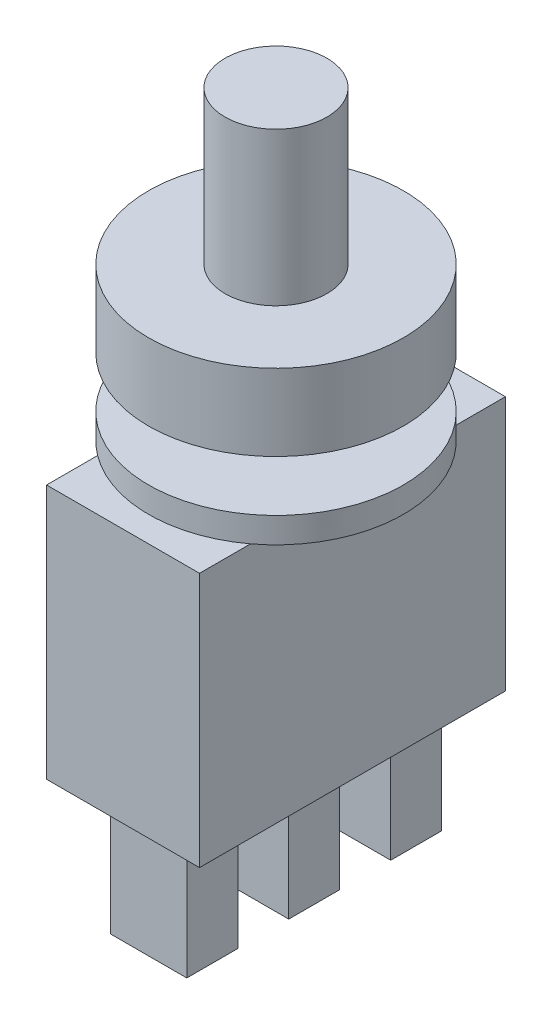
from build123d import *

# Parameters (mm, degrees)
ESQUISSE1_R      = 5
EXTRUSION1_DEPTH = 3
ESQUISSE2_R      = 2
EXTRUSION2_DEPTH = 6
ESQUISSE3_R      = 2
EXTRUSION3_DEPTH = 2
ESQUISSE4_R      = 5
EXTRUSION4_DEPTH = 1
ESQUISSE5_W      = 6
ESQUISSE5_H      = 12
EXTRUSION5_DEPTH = 10
ESQUISSE6_W      = 3
ESQUISSE6_H      = 2
EXTRUSION6_DEPTH = 5


with BuildPart() as part:
    # Esquisse1 → Extrusion1 (new body)
    with BuildSketch(Plane(origin=(0, 0, 0), x_dir=(1, 0, 0), z_dir=(0, 1, 0))):
        Circle(ESQUISSE1_R)
    extrude(amount=EXTRUSION1_DEPTH)

    # Esquisse2 → Extrusion2 (add)
    with BuildSketch(Plane(origin=(0, 3, 0), x_dir=(-1, 0, 0), z_dir=(0, 1, 0))):
        Circle(ESQUISSE2_R)
    extrude(amount=EXTRUSION2_DEPTH)

    # Esquisse3 → Extrusion3 (add)
    with BuildSketch(Plane.XZ):
        Circle(ESQUISSE3_R)
    extrude(amount=EXTRUSION3_DEPTH)

    # Esquisse4 → Extrusion4 (add)
    with BuildSketch(Plane.XZ.offset(2)):
        Circle(ESQUISSE4_R)
    extrude(amount=EXTRUSION4_DEPTH)

    # Esquisse5 → Extrusion5 (add)
    with BuildSketch(Plane.XZ.offset(3)):
        Rectangle(ESQUISSE5_W, ESQUISSE5_H)
    extrude(amount=EXTRUSION5_DEPTH)

    # Esquisse6 → Extrusion6 (add)
    with BuildSketch(Plane.XZ.offset(13)):
        with Locations((0, 4)):
            Rectangle(ESQUISSE6_W, ESQUISSE6_H)
        Rectangle(ESQUISSE6_W, ESQUISSE6_H)
        with Locations((0, -4)):
            Rectangle(ESQUISSE6_W, ESQUISSE6_H)
    extrude(amount=EXTRUSION6_DEPTH)


solid = part.part
